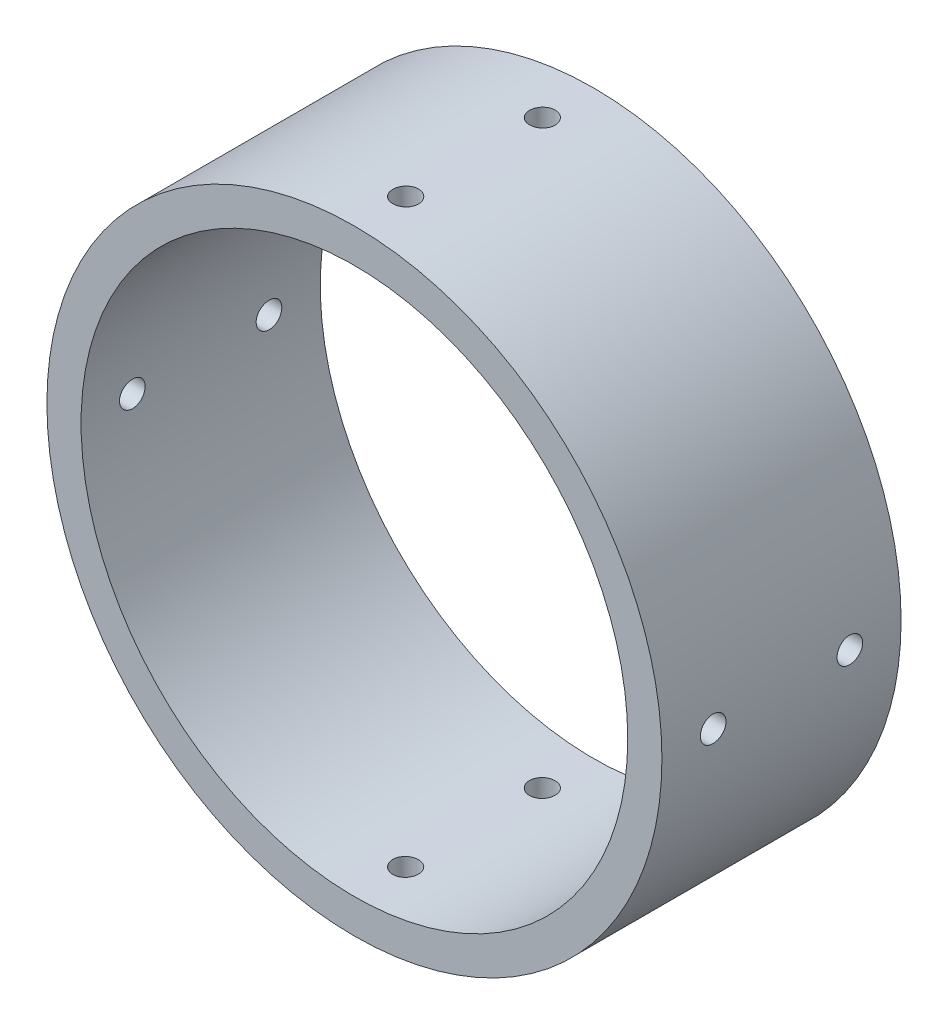
from build123d import *

# Parameters (mm, degrees)
SKETCH1_R           = 18
SKETCH1_R_2         = 16
BOSS_EXTRUDE1_DEPTH = 14
SKETCH2_R           = 0.75
CUT_EXTRUDE1_DEPTH  = 5
CIRPATTERN1_COUNT   = 4


with BuildPart() as part:
    # Sketch1 → Boss-Extrude1 (new body)
    with BuildSketch(Plane.XY):
        Circle(SKETCH1_R)
        Circle(SKETCH1_R_2, mode=Mode.SUBTRACT)
    extrude(amount=BOSS_EXTRUDE1_DEPTH)

    # Sketch2 → Cut-Extrude1 (cut)
    with BuildSketch(Plane(origin=(0, 18, 0), x_dir=(1, 0, 0), z_dir=(0, 1, 0))):
        with Locations((0, -3)):
            Circle(SKETCH2_R)
        with Locations((0, -11)):
            Circle(SKETCH2_R)
    cut_extrude1 = extrude(amount=-CUT_EXTRUDE1_DEPTH, mode=Mode.SUBTRACT)

    # CirPattern1: Cut-Extrude1 ×4 about axis
    cirpattern1_axis = Axis((0, 0, 14), (0, 0, 1))
    for i in range(1, CIRPATTERN1_COUNT):
        add(cut_extrude1.rotate(cirpattern1_axis, i * 360 / CIRPATTERN1_COUNT), mode=Mode.SUBTRACT)


solid = part.part
